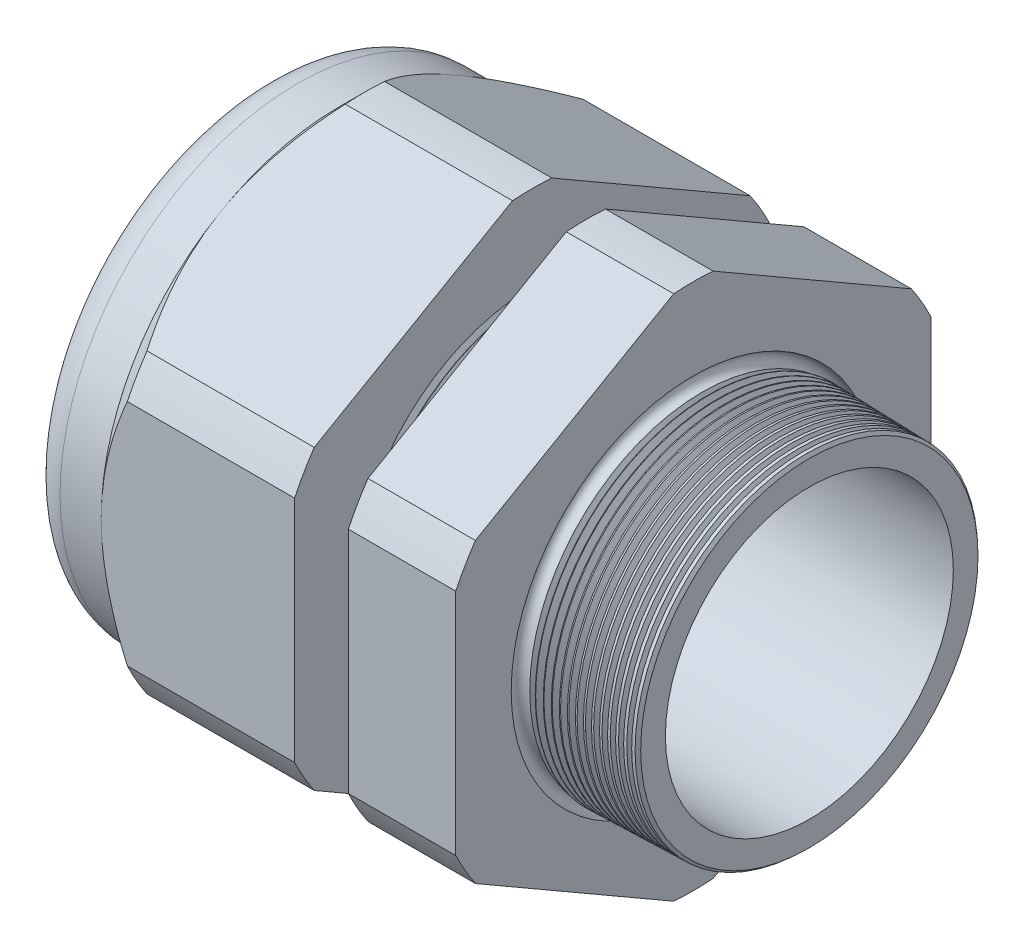
from build123d import *

# Parameters (mm, degrees)
SKETCH12_OUTSIDE_W = 140.582
SKETCH12_OUTSIDE_H = 140.582
CUT_EXTRUDE2_DEPTH = 53.5600168
FILLET4_R          = 3.81
SKETCH19_OUTSIDE_W = 83.088
SKETCH19_OUTSIDE_H = 88.928
SKETCH19_OUTSIDE_R = 26.543
CUT_EXTRUDE3_DEPTH = 3.99796
CUT_EXTRUDE3_DRAFT = -45
CHAMFER1_SIZE      = 0.260919487
CHAMFER1_SIZE2     = 0.254
SKETCH21_R         = 16.002
PLUG_DEPTH         = 12.7
SKETCH22_R         = 15.748
CUT_EXTRUDE4_DEPTH = 0.508
SKETCH27_R         = 4.445
PLUGHOLES_DEPTH    = 61.452
CIRPATTERN1_COUNT  = 5
LPATTERN1_COUNT    = 8
LPATTERN1_PITCH    = 0.762
LPATTERN2_COUNT    = 15
LPATTERN2_PITCH    = 0.889
SKETCH32_R         = 0.889


with BuildPart() as part:
    # Sketch10 → Revolve2 (revolve)
    with BuildSketch(Plane.XY, mode=Mode.PRIVATE) as revolve2_sk:
        Polygon((-55.88, 16.002), (-25.87759112, 16.002), (5.08, 16.080346947), (5.08, 19.128346947), (-7.874, 19.467559375), (-7.874, 53.086), (-19.873976, 53.086), (-19.873976, 19.781789805), (-25.87759112, 19.939), (-25.87759112, 53.086), (-47.4800168, 53.086), (-47.4800168, 26.543), (-55.88, 26.543), align=None)
    revolve(revolve2_sk.sketch.rotate(Axis((0, 0, 0), (-1, 0, 0)), 90), axis=Axis((0, 0, 0), (-1, 0, 0)))  # turned: the seam where the file's is

    # Sketch12 outside → Cut-Extrude2 (cut, through all)
    with BuildSketch(Plane.ZY.offset(47.4800168)):
        Rectangle(SKETCH12_OUTSIDE_W, SKETCH12_OUTSIDE_H)
        with BuildLine():
            Line((-2.19715092, 29.380690715), (-24.34584908, 16.59313387))
            ThreePointArc((-24.34584908, 16.59313387), (-25.515472645, 14.731365), (-26.543, 12.787556845))
            Line((-26.543, 12.787556845), (-26.543, -12.787556845))
            ThreePointArc((-26.543, -12.787556845), (-25.515472645, -14.731365), (-24.34584908, -16.59313387))
            Line((-24.34584908, -16.59313387), (-2.19715092, -29.380690715))
            ThreePointArc((-2.19715092, -29.380690715), (0, -29.46273), (2.19715092, -29.380690715))
            Line((2.19715092, -29.380690715), (24.34584908, -16.59313387))
            ThreePointArc((24.34584908, -16.59313387), (25.515472645, -14.731365), (26.543, -12.787556845))
            Line((26.543, -12.787556845), (26.543, 12.787556845))
            ThreePointArc((26.543, 12.787556845), (25.515472645, 14.731365), (24.34584908, 16.59313387))
            Line((24.34584908, 16.59313387), (2.19715092, 29.380690715))
            ThreePointArc((2.19715092, 29.380690715), (0, 29.46273), (-2.19715092, 29.380690715))
        make_face(mode=Mode.SUBTRACT)
    extrude(amount=-CUT_EXTRUDE2_DEPTH, mode=Mode.SUBTRACT)

    # Fillet4
    fillet4_edges = [part.edges().sort_by_distance(p)[0] for p in [
        (-55.88, 0, 26.543),
    ]]
    fillet(fillet4_edges, radius=FILLET4_R)


with BuildPart() as cut_extrude3_tool:
    # Sketch19 outside → Cut-Extrude3 (with draft: the straight prism first)
    with BuildSketch(Plane.ZY.offset(47.4800168)):
        Rectangle(SKETCH19_OUTSIDE_W, SKETCH19_OUTSIDE_H)
        Circle(SKETCH19_OUTSIDE_R, mode=Mode.SUBTRACT)
    extrude(amount=-CUT_EXTRUDE3_DEPTH)
    # Cut-Extrude3: the draft: its side faces are tilted about the plane it starts from
    cut_extrude3_sides = [cut_extrude3_tool.faces().sort_by_distance(p)[0] for p in [
        (-45.4810368, -44.464, 0),
        (-45.4810368, 0, 41.544),
        (-45.4810368, 44.464, 0),
        (-45.4810368, 0, -41.544),
        (-45.4810368, 0, -26.543),
    ]]
    draft(cut_extrude3_sides, Plane.ZY.offset(47.4800168), CUT_EXTRUDE3_DRAFT)


with BuildPart() as part_1:
    add(part.part)

    # Cut-Extrude3: cut by cut_extrude3_tool
    add(cut_extrude3_tool.part, mode=Mode.SUBTRACT)

    # Chamfer1
    chamfer1_edges = [part_1.edges().sort_by_distance(p)[0] for p in [
        (5.08, 0, 19.128346947),
    ]]
    chamfer1_side = [part_1.faces().sort_by_distance(p)[0] for p in [
        (5.08, 0, 16.621378301),
    ]]
    chamfer(chamfer1_edges, length=CHAMFER1_SIZE, length2=CHAMFER1_SIZE2, reference=chamfer1_side[0])

    # Sketch29 → Cut-Revolve1 (revolve, cut)
    with BuildSketch(Plane.XY, mode=Mode.PRIVATE) as cut_revolve1_sk:
        Polygon((-25.87759112, 19.939), (-25.144607539, 19.919806149), (-25.527721692, 19.294620673), align=None)
    cut_revolve1 = revolve(cut_revolve1_sk.sketch.rotate(Axis((0, 0, 0), (-1, 0, 0)), 90), axis=Axis((0, 0, 0), (-1, 0, 0)), mode=Mode.SUBTRACT)  # turned: the seam where the file's is

    # LPattern1: Cut-Revolve1 ×8
    with Locations(*[(i * LPATTERN1_PITCH, 0, 0) for i in range(1, LPATTERN1_COUNT)]):
        add(cut_revolve1, mode=Mode.SUBTRACT)

    # Sketch30 → Cut-Revolve2 (revolve, cut)
    with BuildSketch(Plane.XY, mode=Mode.PRIVATE) as cut_revolve2_sk:
        Polygon((-7.874, 19.467559375), (-6.994419703, 19.444526754), (-7.454156686, 18.694304183), align=None)
    cut_revolve2 = revolve(cut_revolve2_sk.sketch.rotate(Axis((0, 0, 0), (-1, 0, 0)), 270), axis=Axis((0, 0, 0), (-1, 0, 0)), mode=Mode.SUBTRACT)  # turned: the seam where the file's is

    # LPattern2: Cut-Revolve2 ×15
    with Locations(*[(i * LPATTERN2_PITCH, 0, 0) for i in range(1, LPATTERN2_COUNT)]):
        add(cut_revolve2, mode=Mode.SUBTRACT)

    # Sketch32 → Cut-Revolve3 (revolve, cut)
    with BuildSketch(Plane.XY, mode=Mode.PRIVATE) as cut_revolve3_sk:
        with Locations((-7.747, 19.467559375)):
            Circle(SKETCH32_R)
    revolve(cut_revolve3_sk.sketch.rotate(Axis((0, 0, 0), (-1, 0, 0)), 270), axis=Axis((0, 0, 0), (-1, 0, 0)), mode=Mode.SUBTRACT)  # turned: the seam where the file's is


with BuildPart() as body_2:
    # Sketch21 → plug (new body)
    with BuildSketch(Plane.ZY.offset(55.88)):
        Circle(SKETCH21_R)
    extrude(amount=-PLUG_DEPTH)

    # Sketch22 → Cut-Extrude4 (cut)
    with BuildSketch(Plane.ZY.offset(55.88)):
        Circle(SKETCH22_R)
    extrude(amount=-CUT_EXTRUDE4_DEPTH, mode=Mode.SUBTRACT)

    # Sketch27 → plugholes (cut, through all)
    with BuildSketch(Plane.ZY.offset(55.372)):
        with Locations((-11.28522, 0)):
            Circle(SKETCH27_R)
    plugholes = extrude(amount=-PLUGHOLES_DEPTH, mode=Mode.SUBTRACT)

    # CirPattern1: plugholes ×5 about axis
    cirpattern1_axis = Axis((0, 0, 0), (1, 0, 0))
    for i in range(1, CIRPATTERN1_COUNT):
        add(plugholes.rotate(cirpattern1_axis, i * 360 / CIRPATTERN1_COUNT), mode=Mode.SUBTRACT)


solid = Compound([part_1.part, body_2.part])
